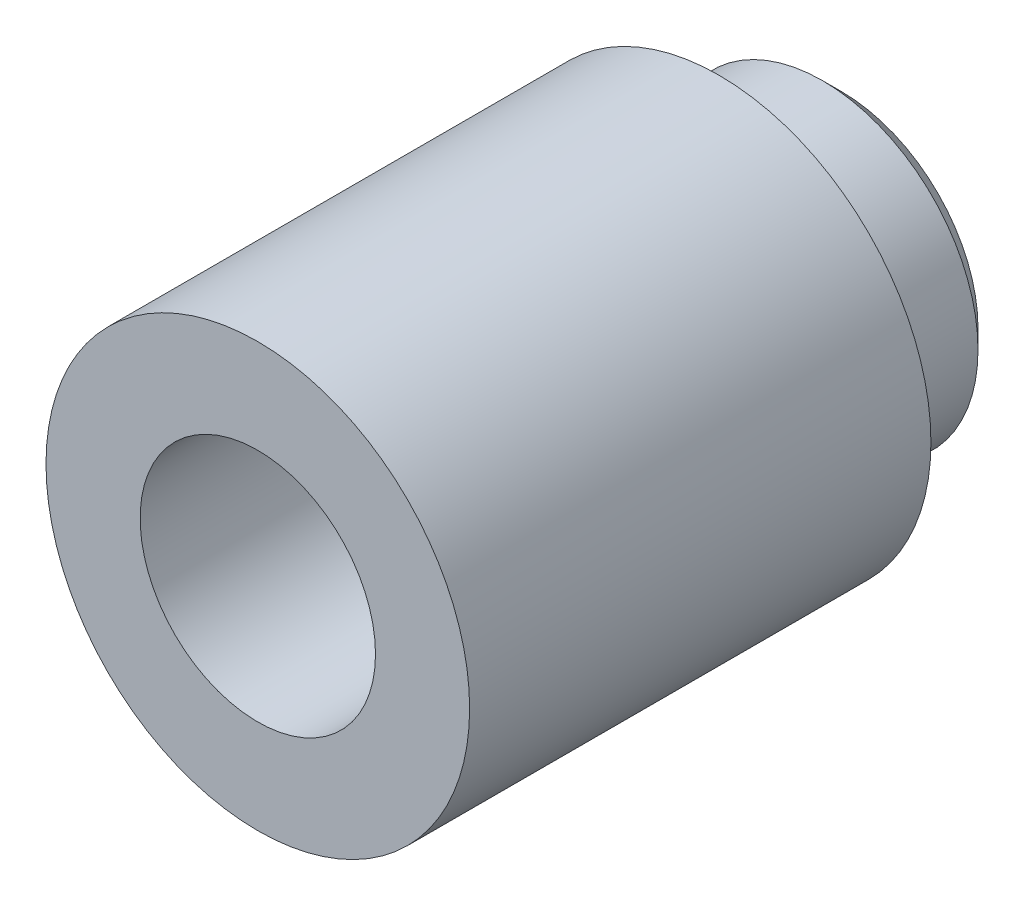
from build123d import *

# Parameters (mm, degrees)
SKETCH1_R           = 2.25
BOSS_EXTRUDE1_DEPTH = 6.2
SKETCH2_OUTSIDE_W   = 8.276
SKETCH2_OUTSIDE_H   = 8.276
SKETCH2_OUTSIDE_R   = 1.65
CUT_EXTRUDE1_DEPTH  = 1.3
SKETCH3_R           = 1.25
CUT_EXTRUDE2_DEPTH  = 7.2
CHAMFER1_SIZE       = 0.2


with BuildPart() as part:
    # Sketch1 → Boss-Extrude1 (new body)
    with BuildSketch(Plane.XY):
        Circle(SKETCH1_R)
    extrude(amount=-BOSS_EXTRUDE1_DEPTH)

    # Sketch2 outside → Cut-Extrude1 (cut)
    with BuildSketch(Plane(origin=(0, 0, -6.2), x_dir=(-1, 0, 0), z_dir=(0, 0, -1))):
        Rectangle(SKETCH2_OUTSIDE_W, SKETCH2_OUTSIDE_H)
        Circle(SKETCH2_OUTSIDE_R, mode=Mode.SUBTRACT)
    extrude(amount=-CUT_EXTRUDE1_DEPTH, mode=Mode.SUBTRACT)

    # Sketch3 → Cut-Extrude2 (cut, through all)
    with BuildSketch(Plane.XY):
        Circle(SKETCH3_R)
    extrude(amount=-CUT_EXTRUDE2_DEPTH, mode=Mode.SUBTRACT)

    # Chamfer1
    chamfer1_edges = [part.edges().sort_by_distance(p)[0] for p in [
        (1.65, 0, -6.2),
    ]]
    chamfer(chamfer1_edges, length=CHAMFER1_SIZE)


solid = part.part
